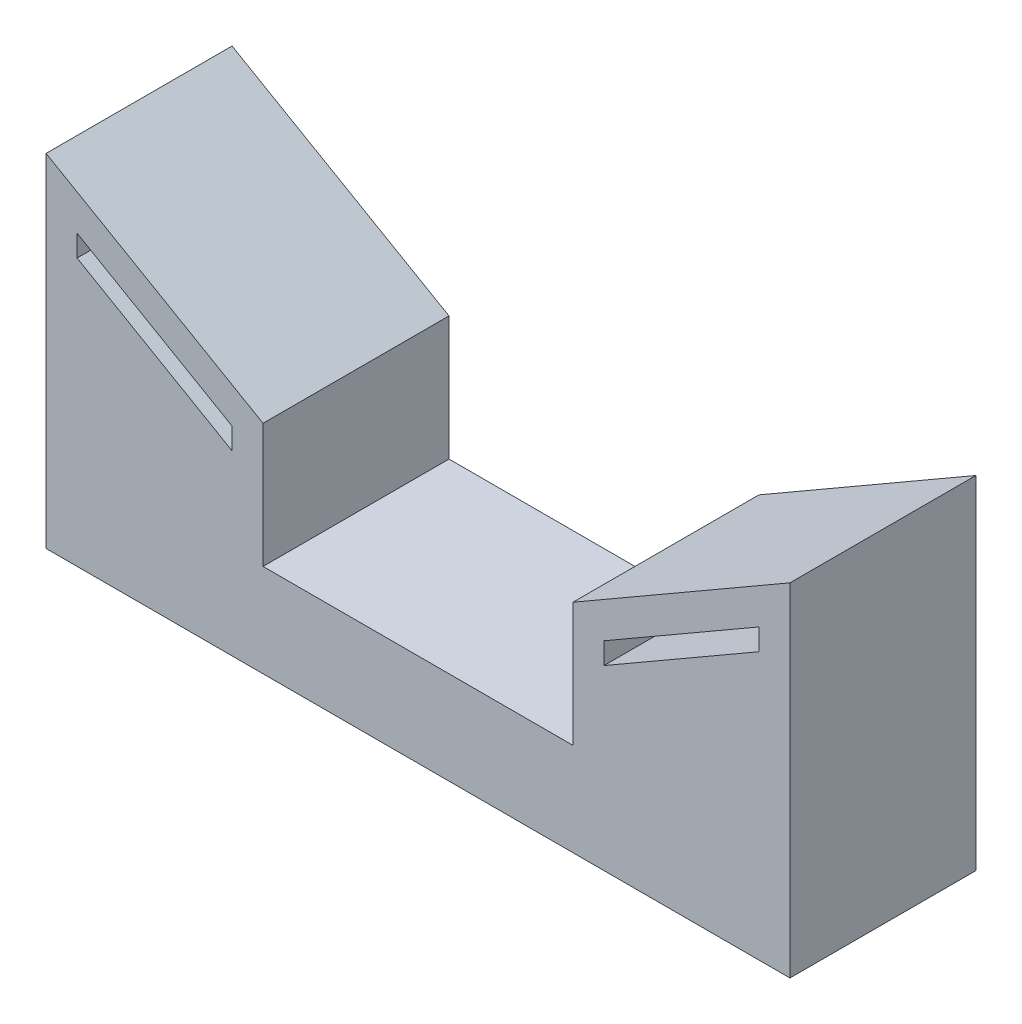
from build123d import *

# Parameters (mm, degrees)
BOSS_EXTRU_1_DEPTH = 30


with BuildPart() as part:
    # Esquisse1 → Boss.-Extru.1 (new body)
    with BuildSketch(Plane.XY):
        Polygon((25, 20), (60, 40.207259422), (60, 0), (60, -15), (-60, -15), (-60, 0), (-60, 40.207259422), (-25, 20), (-25, 0), (25, 0), align=None)
        Polygon((30, 17.113248654), (55, 31.547005384), (55, 28.082903769), (30, 13.649147039), align=None, mode=Mode.SUBTRACT)
        Polygon((-30, 17.113248654), (-30, 13.649147039), (-55, 28.082903769), (-55, 31.547005384), align=None, mode=Mode.SUBTRACT)
    extrude(amount=BOSS_EXTRU_1_DEPTH)


solid = part.part
